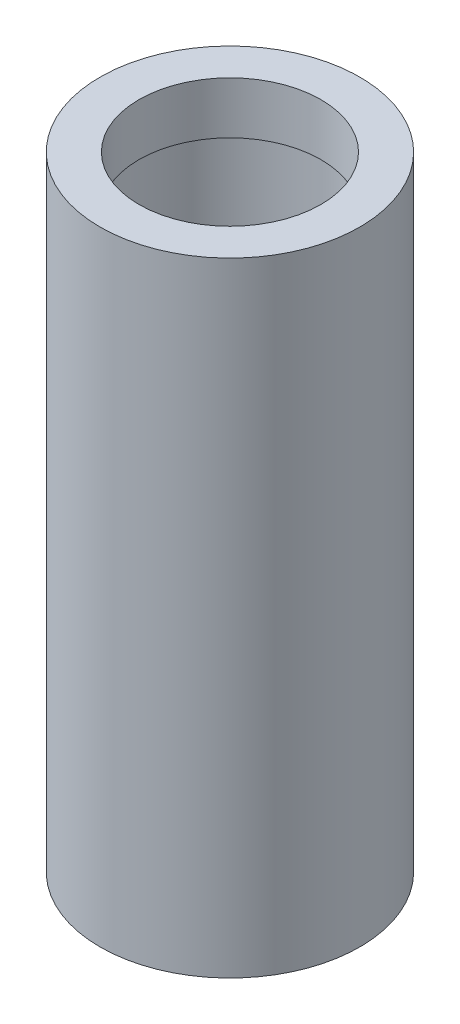
from build123d import *

# Parameters (mm, degrees)
SKETCH1_R           = 25
SKETCH1_R_2         = 20
BOSS_EXTRUDE1_DEPTH = 120
SKETCH2_R           = 20
SKETCH2_R_2         = 17.5
BOSS_EXTRUDE2_DEPTH = 10
SKETCH3_R           = 20
SKETCH3_R_2         = 10
BOSS_EXTRUDE3_DEPTH = 10


with BuildPart() as part:
    # Sketch1 → Boss-Extrude1 (new body)
    with BuildSketch(Plane(origin=(0, 0, 0), x_dir=(1, 0, 0), z_dir=(0, 1, 0))):
        Circle(SKETCH1_R)
        Circle(SKETCH1_R_2, mode=Mode.SUBTRACT)
    extrude(amount=BOSS_EXTRUDE1_DEPTH)

    # Sketch2 → Boss-Extrude2 (add)
    with BuildSketch(Plane(origin=(0, 120, 0), x_dir=(1, 0, 0), z_dir=(0, 1, 0))):
        Circle(SKETCH2_R)
        Circle(SKETCH2_R_2, mode=Mode.SUBTRACT)
    extrude(amount=-BOSS_EXTRUDE2_DEPTH)

    # Sketch3 → Boss-Extrude3 (add)
    with BuildSketch(Plane(origin=(0, 0, 0), x_dir=(-1, 0, 0), z_dir=(0, -1, 0))):
        Circle(SKETCH3_R)
        Circle(SKETCH3_R_2, mode=Mode.SUBTRACT)
    extrude(amount=-BOSS_EXTRUDE3_DEPTH)


solid = part.part
